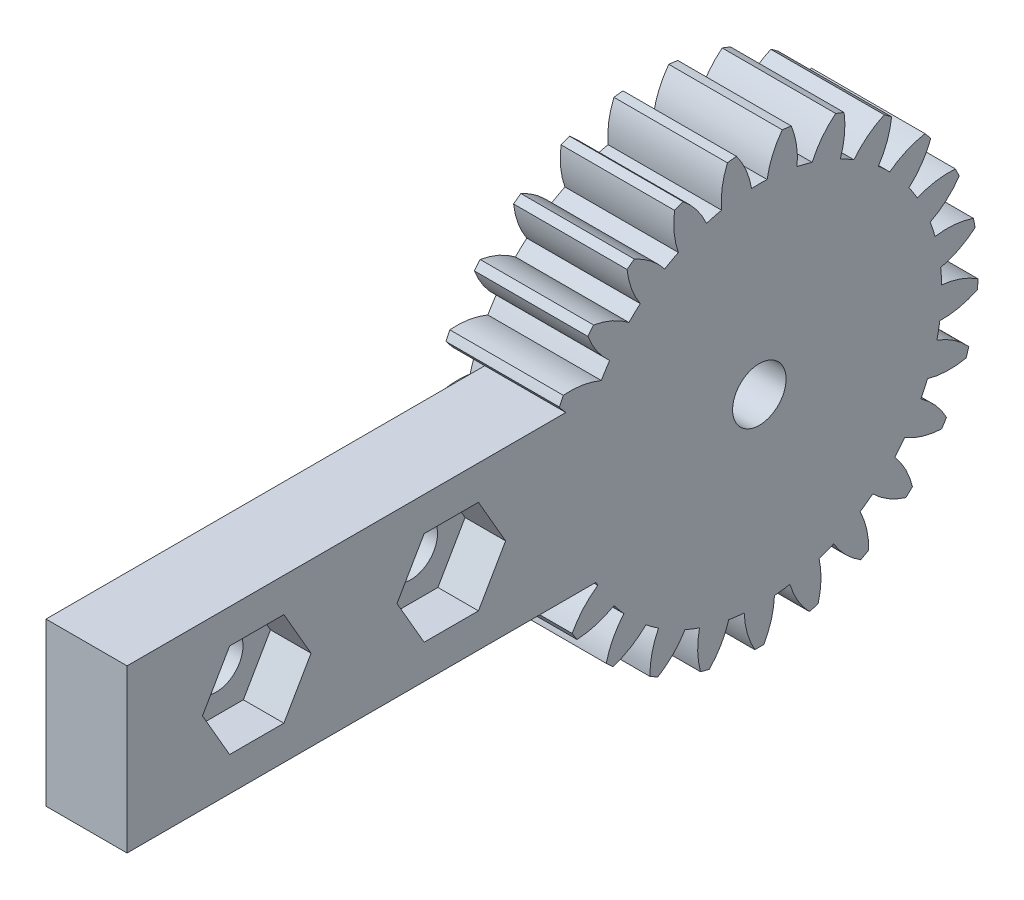
from build123d import *

# Parameters (mm, degrees)
BASPROSKE_W         = 7
BASPROSKE_H         = 13.5
TOOTHCUT_DEPTH      = 21.334699408
TEETHCUTS_COUNT     = 25
TEETHCUTS_ANGLE     = 345.6
BORSKE_R            = 0.4
BORE_DEPTH          = 50.0000508
SKETCH_1_R          = 1.65
CUT_EXTRUDE_1_DEPTH = 10
SKETCH_2_W          = 30
SKETCH_2_H          = 10
SKETCH_2_R          = 1.65
EXTRUDE_2_DEPTH     = 5
CUT_EXTRUDE_2_DEPTH = 2.5


with BuildPart() as part:
    # BasProSke → Base-Revolve (revolve)
    with BuildSketch(Plane(origin=(0, 0, 0), x_dir=(1, 0, 0), z_dir=(0, 1, 0)), mode=Mode.PRIVATE) as base_revolve_sk:
        with Locations((3.5, 6.75)):
            Rectangle(BASPROSKE_W, BASPROSKE_H)
    revolve(base_revolve_sk.sketch.rotate(Axis((-10, 0, 0), (1, 0, 0)), 180), axis=Axis((-10, 0, 0), (1, 0, 0)))

    # TooCutSke → ToothCut (cut, through all)
    with BuildSketch(Plane(origin=(0, 0, 0), x_dir=(0, 0, -1), z_dir=(1, 0, 0))):
        with BuildLine():
            ThreePointArc((0.480087995, 11.238750665), (0, 11.249), (-0.480087995, 11.238750665))
            ThreePointArc((-0.480087995, 11.238750665), (-0.821124963, 12.40220054), (-1.432168974, 13.449361962))
            ThreePointArc((-1.432168974, 13.449361962), (0, 13.5254), (1.432168974, 13.449361962))
            ThreePointArc((1.432168974, 13.449361962), (0.821124963, 12.40220054), (0.480087995, 11.238750665))
        make_face()
    toothcut = extrude(amount=TOOTHCUT_DEPTH, mode=Mode.SUBTRACT)

    # TeethCuts: ToothCut ×25 about axis
    teethcuts_axis = Axis((-10, 0, 0), (1, 0, 0))
    for i in range(1, TEETHCUTS_COUNT):
        add(toothcut.rotate(teethcuts_axis, i * TEETHCUTS_ANGLE / (TEETHCUTS_COUNT - 1)), mode=Mode.SUBTRACT)

    # BorSke → Bore (cut, symmetric)
    with BuildSketch(Plane(origin=(0, 0, 0), x_dir=(0, 0, -1), z_dir=(1, 0, 0))):
        with Locations(Location((0, 0, 0), (0, 0, 180))):
            Circle(BORSKE_R)
    extrude(amount=BORE_DEPTH, both=True, mode=Mode.SUBTRACT)

    # 草图1 → 切除-拉伸1 (cut)
    with BuildSketch(Plane(origin=(7, 0, 0), x_dir=(0, 0, -1), z_dir=(1, 0, 0))):
        Circle(SKETCH_1_R)
    extrude(amount=-CUT_EXTRUDE_1_DEPTH, mode=Mode.SUBTRACT)

    # 草图2 → 凸台-拉伸2 (add)
    with BuildSketch(Plane(origin=(7, 0, 0), x_dir=(0, 0, -1), z_dir=(1, 0, 0))):
        with Locations((-24, 0)):
            Rectangle(SKETCH_2_W, SKETCH_2_H)
        with Locations((-31, 0)):
            Circle(SKETCH_2_R, mode=Mode.SUBTRACT)
        with Locations((-19, 0)):
            Circle(SKETCH_2_R, mode=Mode.SUBTRACT)
    extrude(amount=-EXTRUDE_2_DEPTH)

    # 草图3 → 切除-拉伸2 (cut)
    with BuildSketch(Plane(origin=(7, 0, 0), x_dir=(0, 0, -1), z_dir=(1, 0, 0))):
        Polygon((-27.651368439, 0), (-29.325684219, 2.9), (-32.674315781, 2.9), (-34.348631561, 0), (-32.674315781, -2.9), (-29.325684219, -2.9), align=None)
        Polygon((-15.651368439, 0), (-17.325684219, 2.9), (-20.674315781, 2.9), (-22.348631561, 0), (-20.674315781, -2.9), (-17.325684219, -2.9), align=None)
    extrude(amount=-CUT_EXTRUDE_2_DEPTH, mode=Mode.SUBTRACT)


solid = part.part
